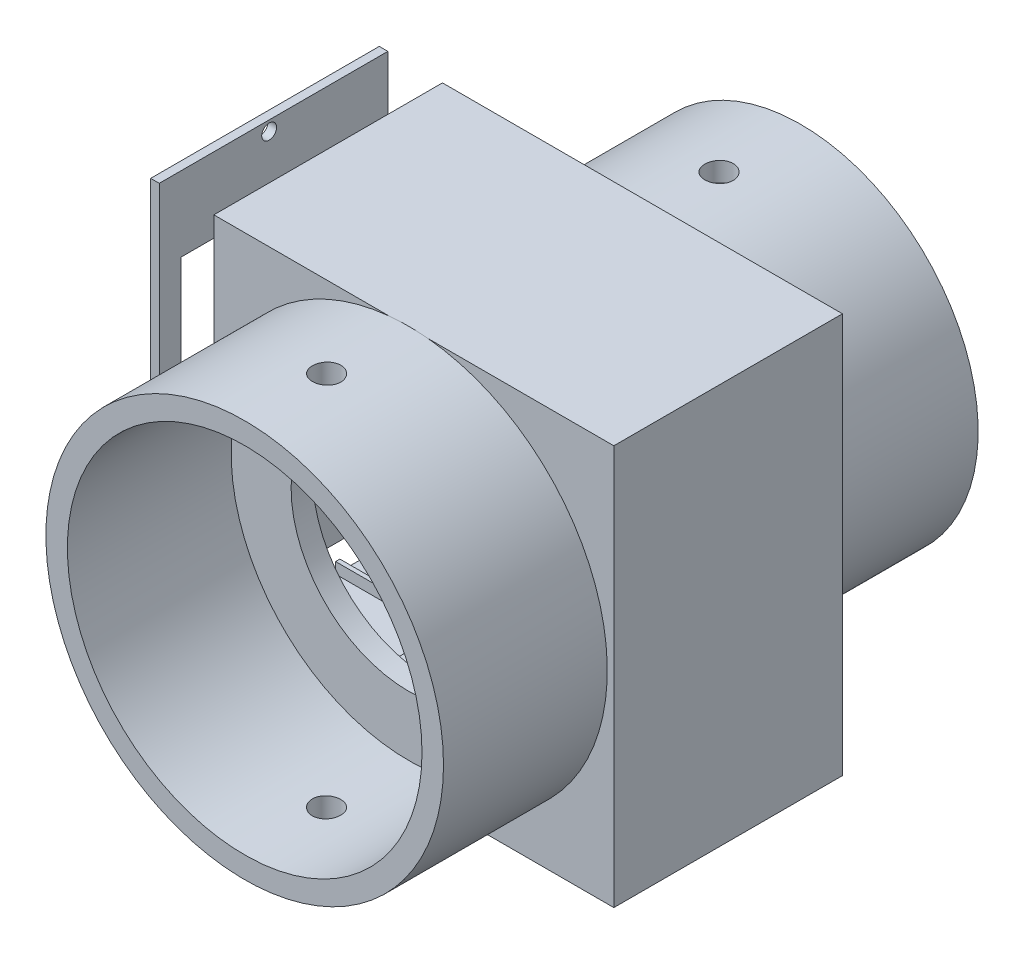
from build123d import *

# Parameters (mm, degrees)
SKETCH1_W                          = 82.55
SKETCH1_H                          = 43.18
BOSS_EXTRUDE1_DEPTH                = 6.500000002
SKETCH3_W                          = 10.169236202
SKETCH3_H                          = 15.494
BOSS_EXTRUDE2_DEPTH                = 13.54328
HOLE_FOR_8_300_SC_NUTS_SP_1_D      = 5.4102
HOLE_FOR_8_300_SC_NUTS_SP_1_DEPTH  = 20.043280002
SKETCH8_W                          = 36.979803104
SKETCH8_H                          = 20.32
BOSS_EXTRUDE3_DEPTH                = 1.27499999
HOLE_FOR_8_300_SC_NUTS_SP_2_D      = 5.4102
HOLE_FOR_8_300_SC_NUTS_SP_2_DEPTH  = 7.774999992
SKETCH14_W                         = 82.55
SKETCH14_H                         = 5
BOSS_EXTRUDE5_DEPTH                = 87.549999906
SKETCH16_W                         = 6.499990096
SKETCH16_H                         = 53.18
BOSS_EXTRUDE6_DEPTH                = 87.549999906
SKETCH19_W                         = 82.55
SKETCH19_H                         = 5
BOSS_EXTRUDE9_DEPTH                = 87.549999906
SKETCH20_R                         = 27.305
CUT_EXTRUDE1_DEPTH                 = 49.18
CUT_EXTRUDE1_DEPTH_BACK            = 6
SKETCH21_W                         = 89.049990096
SKETCH21_H                         = 53.18
BOSS_EXTRUDE10_DEPTH               = 5.50000016
SKETCH25_W                         = 53.18
SKETCH25_H                         = 93.050000066
SKETCH25_W_2                       = 43.18
SKETCH25_H_2                       = 81.049999904
BOSS_EXTRUDE11_DEPTH               = 4.000000096
SKETCH26_R                         = 46.24998878
SKETCH26_R_2                       = 41.24999878
BOSS_EXTRUDE12_DEPTH               = 38.1
SKETCH27_R                         = 41.24999878
SKETCH27_R_2                       = 36.75001032
BOSS_EXTRUDE13_DEPTH               = 38.1
M6_CLEARANCE_HOLE1_D               = 6.6
M6_CLEARANCE_HOLE2_D               = 6.6
SKETCH35_W                         = 86.550000096
SKETCH35_H                         = 1
BOSS_EXTRUDE14_DEPTH               = 2.54
SKETCH37_W                         = 86.550000096
SKETCH37_H                         = 1
BOSS_EXTRUDE15_DEPTH               = 2.54
SKETCH39_W                         = 53.18
SKETCH39_H                         = 93.050000066
BOSS_EXTRUDE17_DEPTH               = 2
TAP_DRILL_FOR_8_32_TAP2_AT_2_COUNT = 2
TAP_DRILL_FOR_8_32_TAP2_AT_2_PITCH = 54.713678959
TAP_DRILL_FOR_8_32_TAP2_AT_3_COUNT = 2
TAP_DRILL_FOR_8_32_TAP2_AT_3_PITCH = 55.69586469
TAP_DRILL_FOR_8_32_TAP2_AT_4_COUNT = 2
TAP_DRILL_FOR_8_32_TAP2_AT_4_PITCH = 88.342480507


with BuildPart() as part:
    # Sketch1 → Boss-Extrude1 (new body)
    with BuildSketch(Plane(origin=(0, 0, 0), x_dir=(1, 0, 0), z_dir=(0, 1, 0))):
        with Locations((-32.452862595, 1.031269084)):
            Rectangle(SKETCH1_W, SKETCH1_H)
    extrude(amount=BOSS_EXTRUDE1_DEPTH)

    # Sketch3 → Boss-Extrude2 (add)
    with BuildSketch(Plane(origin=(0, 6.500000002, 0), x_dir=(1, 0, 0), z_dir=(0, 1, 0))):
        with Locations((-32.452862595, 12.874269084)):
            Rectangle(SKETCH3_W, SKETCH3_H)
    extrude(amount=BOSS_EXTRUDE2_DEPTH)

    # Hole for #8 300® SC Nuts (SP)1
    with Locations(Plane(origin=(0, 20.043280002, 0), x_dir=(1, 0, 0), z_dir=(0, 1, 0))):
        with Locations((-32.452862595, 12.327269084)):
            Hole(HOLE_FOR_8_300_SC_NUTS_SP_1_D / 2, depth=HOLE_FOR_8_300_SC_NUTS_SP_1_DEPTH)

    # Sketch8 → Boss-Extrude3 (add)
    with BuildSketch(Plane(origin=(0, 6.500000002, 0), x_dir=(1, 0, 0), z_dir=(0, 1, 0))):
        with Locations((-33.976224547, -7.398730916)):
            Rectangle(SKETCH8_W, SKETCH8_H)
    extrude(amount=BOSS_EXTRUDE3_DEPTH)

    # Hole for #8 300® SC Nuts (SP)2
    with Locations(Plane(origin=(0, 7.774999992, 0), x_dir=(1, 0, 0), z_dir=(0, 1, 0))):
        with Locations((-32.452862595, -8.058730866), (-45.152862595, -8.058730866)):
            Hole(HOLE_FOR_8_300_SC_NUTS_SP_2_D / 2, depth=HOLE_FOR_8_300_SC_NUTS_SP_2_DEPTH)

    # Sketch14 → Boss-Extrude5 (add)
    with BuildSketch(Plane(origin=(0, 0, 0), x_dir=(-1, 0, 0), z_dir=(0, -1, 0))):
        with Locations((32.452862595, 25.121269084)):
            Rectangle(SKETCH14_W, SKETCH14_H)
    extrude(amount=-BOSS_EXTRUDE5_DEPTH)

    # Sketch16 → Boss-Extrude6 (add)
    with BuildSketch(Plane(origin=(0, 0, 0), x_dir=(-1, 0, 0), z_dir=(0, -1, 0))):
        with Locations((-12.072132453, 1.031269084)):
            Rectangle(SKETCH16_W, SKETCH16_H)
    extrude(amount=-BOSS_EXTRUDE6_DEPTH)

    # Sketch19 → Boss-Extrude9 (add)
    with BuildSketch(Plane.XZ):
        with Locations((-32.452862595, 23.058730916)):
            Rectangle(SKETCH19_W, SKETCH19_H)
    extrude(amount=-BOSS_EXTRUDE9_DEPTH)

    # Sketch20 → Cut-Extrude1 (cut, two sides)
    with BuildSketch(Plane.XY.offset(-22.621269084)) as cut_extrude1_sk:
        with Locations((-32.452862595, 47.024999954)):
            Circle(SKETCH20_R)
    extrude(amount=CUT_EXTRUDE1_DEPTH, mode=Mode.SUBTRACT)
    extrude(cut_extrude1_sk.sketch, amount=-CUT_EXTRUDE1_DEPTH_BACK, mode=Mode.SUBTRACT)

    # Sketch21 → Boss-Extrude10 (add)
    with BuildSketch(Plane(origin=(0, 87.549999906, 0), x_dir=(1, 0, 0), z_dir=(0, 1, 0))):
        with Locations((-29.202867547, 1.031269084)):
            Rectangle(SKETCH21_W, SKETCH21_H)
    extrude(amount=BOSS_EXTRUDE10_DEPTH)

    # Sketch25 → Boss-Extrude11 (add)
    with BuildSketch(Plane.ZY.offset(73.727862595)):
        with Locations((-1.031269084, 46.525000033)):
            Rectangle(SKETCH25_W, SKETCH25_H)
        with Locations((-1.031269084, 47.024999954)):
            Rectangle(SKETCH25_W_2, SKETCH25_H_2, mode=Mode.SUBTRACT)
    extrude(amount=BOSS_EXTRUDE11_DEPTH)

    # Sketch26 → Boss-Extrude12 (add)
    with BuildSketch(Plane.XY.offset(25.558730916)):
        with Locations((-32.452862595, 47.024999954)):
            Circle(SKETCH26_R)
        with Locations((-32.452862595, 47.024999954)):
            Circle(SKETCH26_R_2, mode=Mode.SUBTRACT)
    extrude(amount=BOSS_EXTRUDE12_DEPTH)

    # Sketch27 → Boss-Extrude13 (add)
    with BuildSketch(Plane(origin=(0, 0, -27.621269084), x_dir=(-1, 0, 0), z_dir=(0, 0, -1))):
        with Locations((32.452862595, 47.024999954)):
            Circle(SKETCH27_R)
        with Locations((32.452862595, 47.024999954)):
            Circle(SKETCH27_R_2, mode=Mode.SUBTRACT)
    extrude(amount=BOSS_EXTRUDE13_DEPTH)

    # M6 Clearance Hole1 (through all)
    with Locations(Plane(origin=(0, 88.274998734, 0), x_dir=(1, 0, 0), z_dir=(0, 1, 0))):
        with Locations((-32.452862595, 46.671269084)):
            Hole(M6_CLEARANCE_HOLE1_D / 2)

    # M6 Clearance Hole2 (through all)
    with Locations(Plane(origin=(0, 93.274988734, 0), x_dir=(1, 0, 0), z_dir=(0, 1, 0))):
        with Locations((-32.452862595, -44.608730916)):
            Hole(M6_CLEARANCE_HOLE2_D / 2)

    # Sketch35 → Boss-Extrude14 (add)
    with BuildSketch(Plane(origin=(0, 6.500000002, 0), x_dir=(1, 0, 0), z_dir=(0, 1, 0))):
        with Locations((-34.452862643, 3.261269084)):
            Rectangle(SKETCH35_W, SKETCH35_H)
    extrude(amount=BOSS_EXTRUDE14_DEPTH)

    # Sketch37 → Boss-Extrude15 (add)
    with BuildSketch(Plane(origin=(0, 6.500000002, 0), x_dir=(1, 0, 0), z_dir=(0, 1, 0))):
        with Locations((-34.452862643, -19.332057389)):
            Rectangle(SKETCH37_W, SKETCH37_H)
    extrude(amount=BOSS_EXTRUDE15_DEPTH)


with BuildPart() as body_2:
    # Sketch39 → Boss-Extrude17 (new body)
    with BuildSketch(Plane.ZY.offset(90.427862691)):
        with Locations((-1.031269084, 46.525000033)):
            Rectangle(SKETCH39_W, SKETCH39_H)
        Polygon((-4.072269098, 75.645648556), (-4.688887234, 6.500000002), (20.558730916, 6.500000002), (20.558730916, 75.645648556), align=None, mode=Mode.SUBTRACT)
    extrude(amount=BOSS_EXTRUDE17_DEPTH)


with BuildPart() as tap_drill_for_8_32_tap2_tool:
    # Sketch44 → Tap Drill for #8-32 Tap2 (revolve)
    with BuildSketch(Plane(origin=(-92.427862691, 90.696240287, 0), x_dir=(0, 0, 1), z_dir=(0, 1, 0))):
        Polygon((0, 0), (0, 21.357806461), (1.7272, 20.32), (1.7272, 0), align=None)
    tap_drill_for_8_32_tap2 = revolve(axis=Axis((-98.777862691, 90.696240287, 0), (1, 0, 0)))


with BuildPart() as part_1:
    add(part.part)

    # Tap Drill for #8-32 Tap2: cut by tap_drill_for_8_32_tap2_tool
    add(tap_drill_for_8_32_tap2_tool.part, mode=Mode.SUBTRACT)


with BuildPart() as body_2_1:
    add(body_2.part)

    # Tap Drill for #8-32 Tap2: cut by tap_drill_for_8_32_tap2_tool
    add(tap_drill_for_8_32_tap2_tool.part, mode=Mode.SUBTRACT)


with BuildPart() as tap_drill_for_8_32_tap2_at_2_tool:
    # Tap Drill for #8-32 Tap2 at 2: Tap Drill for #8-32 Tap2 ×2
    with Locations(*[Vector(0, -0.906965442, 0.421205042) * (i * TAP_DRILL_FOR_8_32_TAP2_AT_2_PITCH) for i in range(1, TAP_DRILL_FOR_8_32_TAP2_AT_2_COUNT)]):
        add(tap_drill_for_8_32_tap2)


with BuildPart() as part_2:
    add(part_1.part)

    # Tap Drill for #8-32 Tap2 at 2: cut by tap_drill_for_8_32_tap2_at_2_tool
    add(tap_drill_for_8_32_tap2_at_2_tool.part, mode=Mode.SUBTRACT)


with BuildPart() as body_2_2:
    add(body_2_1.part)

    # Tap Drill for #8-32 Tap2 at 2: cut by tap_drill_for_8_32_tap2_at_2_tool
    add(tap_drill_for_8_32_tap2_at_2_tool.part, mode=Mode.SUBTRACT)


with BuildPart() as tap_drill_for_8_32_tap2_at_3_tool:
    # Tap Drill for #8-32 Tap2 at 3: Tap Drill for #8-32 Tap2 ×2
    with Locations(*[Vector(0, -0.890971283, -0.454059658) * (i * TAP_DRILL_FOR_8_32_TAP2_AT_3_PITCH) for i in range(1, TAP_DRILL_FOR_8_32_TAP2_AT_3_COUNT)]):
        add(tap_drill_for_8_32_tap2)


with BuildPart() as part_3:
    add(part_2.part)

    # Tap Drill for #8-32 Tap2 at 3: cut by tap_drill_for_8_32_tap2_at_3_tool
    add(tap_drill_for_8_32_tap2_at_3_tool.part, mode=Mode.SUBTRACT)


with BuildPart() as body_2_3:
    add(body_2_2.part)

    # Tap Drill for #8-32 Tap2 at 3: cut by tap_drill_for_8_32_tap2_at_3_tool
    add(tap_drill_for_8_32_tap2_at_3_tool.part, mode=Mode.SUBTRACT)


with BuildPart() as tap_drill_for_8_32_tap2_at_4_tool:
    # Tap Drill for #8-32 Tap2 at 4: Tap Drill for #8-32 Tap2 ×2
    with Locations(*[(0, -i * TAP_DRILL_FOR_8_32_TAP2_AT_4_PITCH, 0) for i in range(1, TAP_DRILL_FOR_8_32_TAP2_AT_4_COUNT)]):
        add(tap_drill_for_8_32_tap2)


with BuildPart() as part_4:
    add(part_3.part)

    # Tap Drill for #8-32 Tap2 at 4: cut by tap_drill_for_8_32_tap2_at_4_tool
    add(tap_drill_for_8_32_tap2_at_4_tool.part, mode=Mode.SUBTRACT)


with BuildPart() as body_2_4:
    add(body_2_3.part)

    # Tap Drill for #8-32 Tap2 at 4: cut by tap_drill_for_8_32_tap2_at_4_tool
    add(tap_drill_for_8_32_tap2_at_4_tool.part, mode=Mode.SUBTRACT)


solid = Compound([part_4.part, body_2_4.part])
